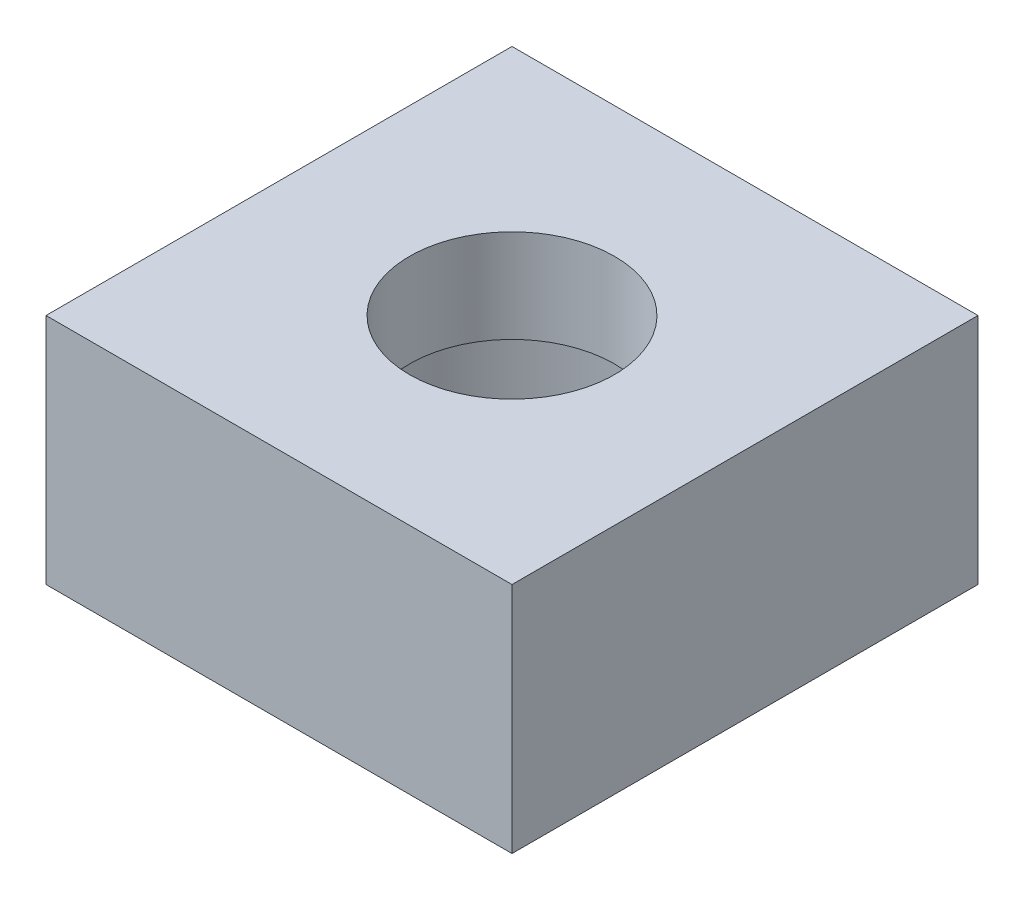
from build123d import *

# Parameters (mm, degrees)
SKETCH1_W           = 10
SKETCH1_H           = 10
SKETCH1_R           = 4
SKETCH1_R_2         = 2.2
BOSS_EXTRUDE1_DEPTH = 5
SKETCH3_R           = 4
SKETCH3_R_2         = 2.2
CUT_EXTRUDE3_DEPTH  = 3


with BuildPart() as part:
    # Sketch1 → Boss-Extrude1 (new body)
    with BuildSketch(Plane(origin=(0, 0, 0), x_dir=(1, 0, 0), z_dir=(0, 1, 0))):
        Rectangle(SKETCH1_W, SKETCH1_H)
        Circle(SKETCH1_R, mode=Mode.SUBTRACT)
        Circle(SKETCH1_R)
        with Locations(Location((0, 0, 0), (0, 0, 270))):
            Circle(SKETCH1_R_2, mode=Mode.SUBTRACT)
    extrude(amount=BOSS_EXTRUDE1_DEPTH)

    # Sketch3 → Cut-Extrude3 (cut)
    with BuildSketch(Plane.XZ):
        with Locations(Location((0, 0, 0), (0, 0, 270))):
            Circle(SKETCH3_R)
        with Locations(Location((0, 0, 0), (0, 0, 270))):
            Circle(SKETCH3_R_2, mode=Mode.SUBTRACT)
    extrude(amount=-CUT_EXTRUDE3_DEPTH, mode=Mode.SUBTRACT)


solid = part.part
